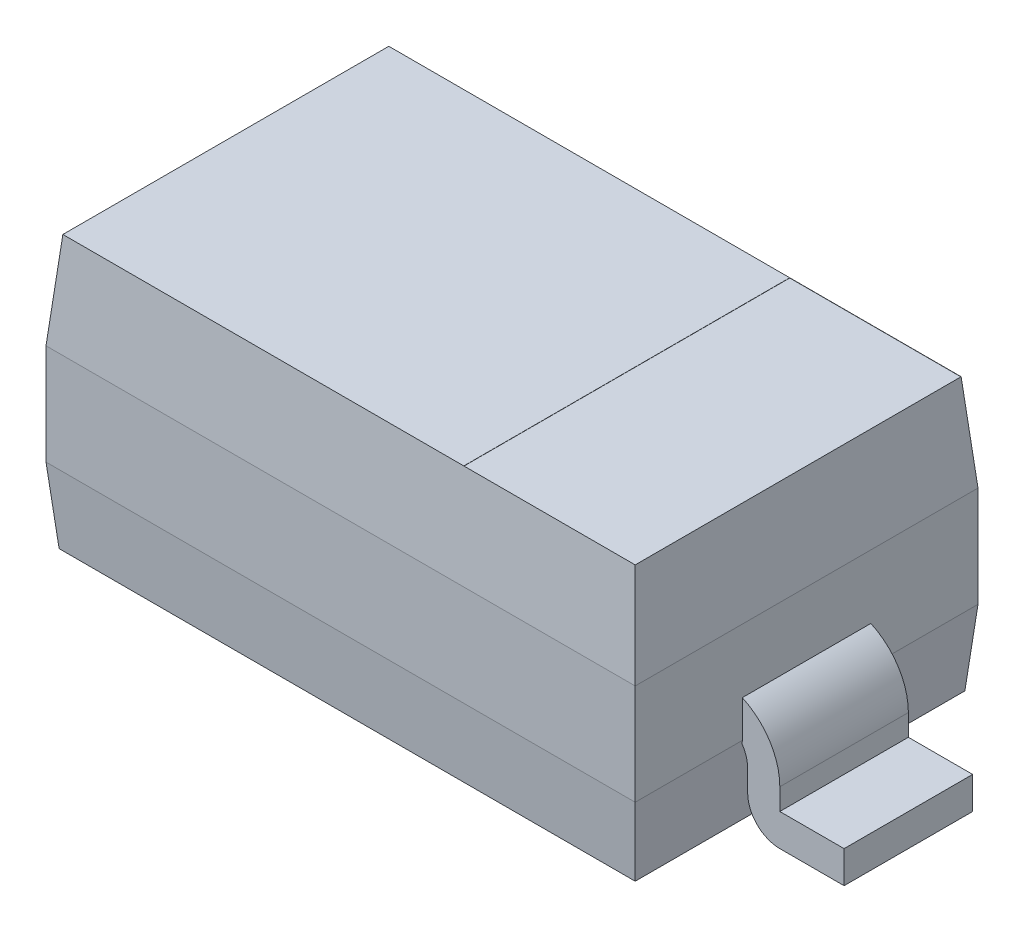
from build123d import *
from OCP.BRepFilletAPI import BRepFilletAPI_MakeChamfer

# Parameters (mm, degrees)
SKETCH1_W                     = 2.75
SKETCH1_H                     = 1.6
BASE_EXTRUDE_DEPTH            = 1.27
CHAMFER1_SIZE                 = 0.45
CHAMFER1_SIZE2                = 0.039369899
CHAMFER3_SIZE                 = 0.35
CHAMFER3_SIZE2                = 0.030621032
BOSS_EXTRUDE_THIN2_DEPTH      = 0.3
BOSS_EXTRUDE_THIN2_DEPTH_BACK = 0.3
SKETCH3_W                     = 0.8
SKETCH3_H                     = 1.521260202
CUT_EXTRUDE1_DEPTH            = 0.001


with BuildPart() as part:
    # Sketch1 → Base-Extrude (new body)
    with BuildSketch(Plane(origin=(0, 0, 0), x_dir=(1, 0, 0), z_dir=(0, 1, 0))):
        Rectangle(SKETCH1_W, SKETCH1_H)
    extrude(amount=BASE_EXTRUDE_DEPTH)

    # Chamfer1: one chamfer whose edges measure the first distance from different faces: ONE call of the kernel's chamfer builder (chamfer() names one face for all edges)
    chamfer1_edges_1 = [part.edges().sort_by_distance(p)[0] for p in [
        (1.375, 1.27, 0),
    ]]
    chamfer1_side_1 = [part.faces().sort_by_distance(p)[0] for p in [
        (1.375, 0.635, 0),
    ]]
    chamfer1_edges_2 = [part.edges().sort_by_distance(p)[0] for p in [
        (0, 1.27, -0.8),
    ]]
    chamfer1_side_2 = [part.faces().sort_by_distance(p)[0] for p in [
        (0, 0.635, -0.8),
    ]]
    chamfer1_edges_3 = [part.edges().sort_by_distance(p)[0] for p in [
        (-1.375, 1.27, 0),
    ]]
    chamfer1_side_3 = [part.faces().sort_by_distance(p)[0] for p in [
        (-1.375, 0.635, 0),
    ]]
    chamfer1_edges_4 = [part.edges().sort_by_distance(p)[0] for p in [
        (0, 1.27, 0.8),
    ]]
    chamfer1_side_4 = [part.faces().sort_by_distance(p)[0] for p in [
        (0, 0.635, 0.8),
    ]]
    chamfer1 = BRepFilletAPI_MakeChamfer(part.part.solid().wrapped)
    for e in chamfer1_edges_1:
        chamfer1.Add(CHAMFER1_SIZE, CHAMFER1_SIZE2, e.wrapped, chamfer1_side_1[0].wrapped)  # the first distance lies on this face
    for e in chamfer1_edges_2:
        chamfer1.Add(CHAMFER1_SIZE, CHAMFER1_SIZE2, e.wrapped, chamfer1_side_2[0].wrapped)  # the first distance lies on this face
    for e in chamfer1_edges_3:
        chamfer1.Add(CHAMFER1_SIZE, CHAMFER1_SIZE2, e.wrapped, chamfer1_side_3[0].wrapped)  # the first distance lies on this face
    for e in chamfer1_edges_4:
        chamfer1.Add(CHAMFER1_SIZE, CHAMFER1_SIZE2, e.wrapped, chamfer1_side_4[0].wrapped)  # the first distance lies on this face
    add(Compound.cast(chamfer1.Shape()), mode=Mode.REPLACE)

    # Chamfer3: one chamfer whose edges measure the first distance from different faces: ONE call of the kernel's chamfer builder (chamfer() names one face for all edges)
    chamfer3_edges_1 = [part.edges().sort_by_distance(p)[0] for p in [
        (0, 0, -0.8),
    ]]
    chamfer3_side_1 = [part.faces().sort_by_distance(p)[0] for p in [
        (0, 0.41, -0.8),
    ]]
    chamfer3_edges_2 = [part.edges().sort_by_distance(p)[0] for p in [
        (1.375, 0, 0),
    ]]
    chamfer3_side_2 = [part.faces().sort_by_distance(p)[0] for p in [
        (1.375, 0.41, 0),
    ]]
    chamfer3_edges_3 = [part.edges().sort_by_distance(p)[0] for p in [
        (0, 0, 0.8),
    ]]
    chamfer3_side_3 = [part.faces().sort_by_distance(p)[0] for p in [
        (0, 0.41, 0.8),
    ]]
    chamfer3_edges_4 = [part.edges().sort_by_distance(p)[0] for p in [
        (-1.375, 0, 0),
    ]]
    chamfer3_side_4 = [part.faces().sort_by_distance(p)[0] for p in [
        (-1.375, 0.41, 0),
    ]]
    chamfer3 = BRepFilletAPI_MakeChamfer(part.part.solid().wrapped)
    for e in chamfer3_edges_1:
        chamfer3.Add(CHAMFER3_SIZE, CHAMFER3_SIZE2, e.wrapped, chamfer3_side_1[0].wrapped)  # the first distance lies on this face
    for e in chamfer3_edges_2:
        chamfer3.Add(CHAMFER3_SIZE, CHAMFER3_SIZE2, e.wrapped, chamfer3_side_2[0].wrapped)  # the first distance lies on this face
    for e in chamfer3_edges_3:
        chamfer3.Add(CHAMFER3_SIZE, CHAMFER3_SIZE2, e.wrapped, chamfer3_side_3[0].wrapped)  # the first distance lies on this face
    for e in chamfer3_edges_4:
        chamfer3.Add(CHAMFER3_SIZE, CHAMFER3_SIZE2, e.wrapped, chamfer3_side_4[0].wrapped)  # the first distance lies on this face
    add(Compound.cast(chamfer3.Shape()), mode=Mode.REPLACE)

    # Sketch2 → Boss-Extrude-Thin2 (add, two sides)
    with BuildSketch(Plane.XY) as boss_extrude_thin2_sk:
        with BuildLine():
            Line((-1.85, 0), (-1.55, 0))
            ThreePointArc((-1.55, 0), (-1.443933983, 0.043933983), (-1.4, 0.15))
            Line((-1.4, 0.15), (-1.4, 0.25))
            ThreePointArc((-1.4, 0.25), (-1.356066017, 0.356066017), (-1.25, 0.4))
            Line((-1.25, 0.4), (1.25, 0.4))
            ThreePointArc((1.25, 0.4), (1.356066017, 0.356066017), (1.4, 0.25))
            Line((1.4, 0.25), (1.4, 0.15))
            ThreePointArc((1.4, 0.15), (1.443933983, 0.043933983), (1.55, 0))
            Line((1.55, 0), (1.85, 0))
            Line((1.85, 0), (1.85, 0.15))
            Line((1.85, 0.15), (1.55, 0.15))
            Line((1.55, 0.15), (1.55, 0.25))
            ThreePointArc((1.55, 0.25), (1.462132034, 0.462132034), (1.25, 0.55))
            Line((1.25, 0.55), (-1.25, 0.55))
            ThreePointArc((-1.25, 0.55), (-1.462132034, 0.462132034), (-1.55, 0.25))
            Line((-1.55, 0.25), (-1.55, 0.15))
            Line((-1.55, 0.15), (-1.85, 0.15))
            Line((-1.85, 0.15), (-1.85, 0))
        make_face()
    extrude(amount=BOSS_EXTRUDE_THIN2_DEPTH)
    extrude(boss_extrude_thin2_sk.sketch, amount=-BOSS_EXTRUDE_THIN2_DEPTH_BACK)

    # Sketch3 → Cut-Extrude1 (cut)
    with BuildSketch(Plane(origin=(0, 1.27, 0), x_dir=(-1, 0, 0), z_dir=(0, 1, 0))):
        with Locations((-0.935630101, 0)):
            Rectangle(SKETCH3_W, SKETCH3_H)
    extrude(amount=-CUT_EXTRUDE1_DEPTH, mode=Mode.SUBTRACT)


solid = part.part
